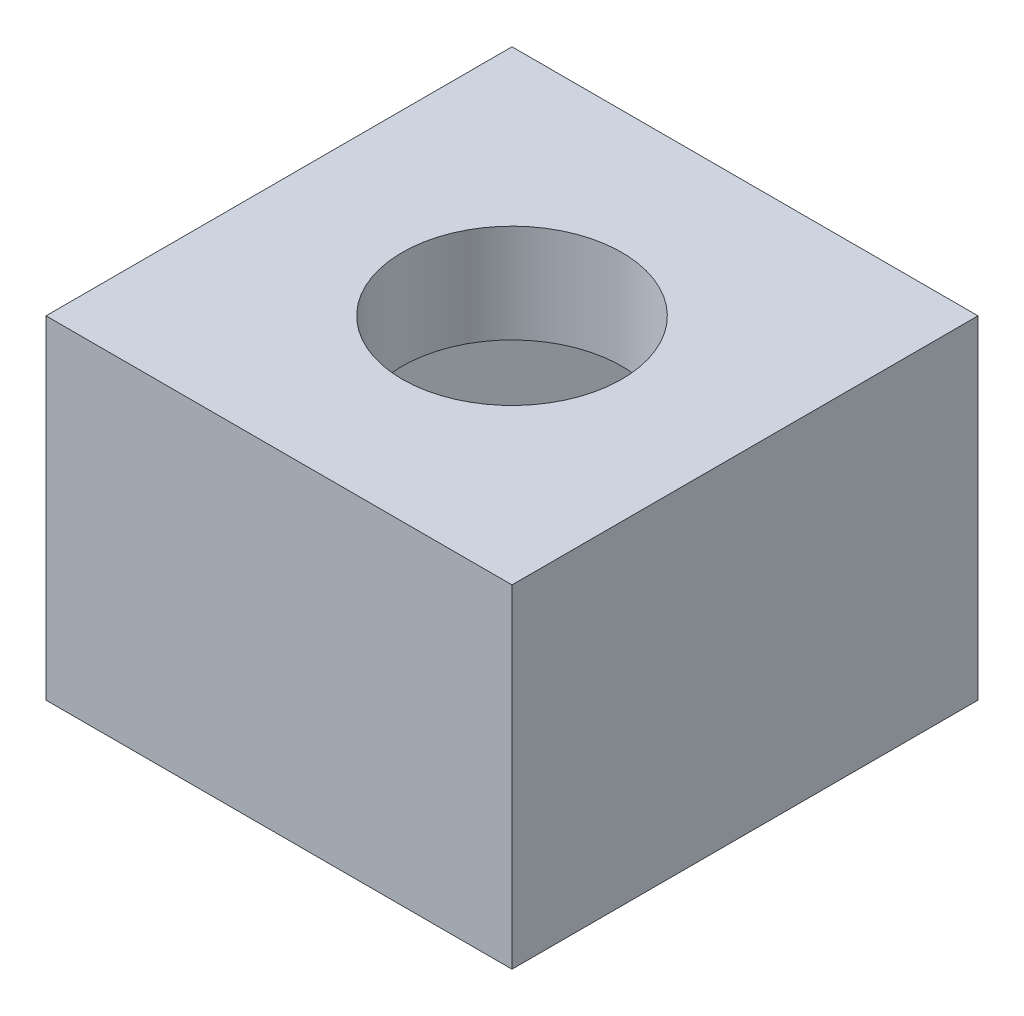
from build123d import *

# Parameters (mm, degrees)
SKETCH1_W           = 7
SKETCH1_H           = 7
BOSS_EXTRUDE1_DEPTH = 5
SKETCH4_R           = 1.65
CUT_EXTRUDE4_DEPTH  = 4
SKETCH6_R           = 1.65
CUT_EXTRUDE6_DEPTH  = 4
SKETCH6_4_R         = 1.65
BOSS_EXTRUDE2_DEPTH = 1.48


with BuildPart() as part:
    # Sketch1 → Boss-Extrude1 (new body)
    with BuildSketch(Plane(origin=(0, 0, 0), x_dir=(1, 0, 0), z_dir=(0, 1, 0))):
        with Locations((-0.67779661, -2.128287226)):
            Rectangle(SKETCH1_W, SKETCH1_H)
    extrude(amount=BOSS_EXTRUDE1_DEPTH)

    # Sketch4 → Cut-Extrude4 (cut)
    with BuildSketch(Plane(origin=(0, 5, 0), x_dir=(1, 0, 0), z_dir=(0, 1, 0))):
        Polygon((-1.544486233, 1.106242481), (-3.912326317, -1.261597603), (-3.045636694, -4.496127311), (0.188893013, -5.362816934), (2.556733098, -2.99497685), (1.690043475, 0.239552858), align=None)
        with Locations((-0.67779661, -2.128287226)):
            Circle(SKETCH4_R, mode=Mode.SUBTRACT)
    extrude(amount=-CUT_EXTRUDE4_DEPTH, mode=Mode.SUBTRACT)

    # Sketch6 → Cut-Extrude6 (cut)
    with BuildSketch(Plane(origin=(0, 5, 0), x_dir=(1, 0, 0), z_dir=(0, 1, 0))):
        with Locations((-0.67779661, -2.128287226)):
            Circle(SKETCH6_R)
    extrude(amount=-CUT_EXTRUDE6_DEPTH, mode=Mode.SUBTRACT)

    # Sketch6_4 → Boss-Extrude2 (add)
    with BuildSketch(Plane(origin=(0, 5, 0), x_dir=(1, 0, 0), z_dir=(0, 1, 0))):
        Polygon((-1.544486233, 1.106242481), (-3.912326317, -1.261597603), (-3.045636694, -4.496127311), (0.188893013, -5.362816934), (2.556733098, -2.99497685), (1.690043475, 0.239552858), align=None)
        with Locations((-0.67779661, -2.128287226)):
            Circle(SKETCH6_4_R, mode=Mode.SUBTRACT)
    extrude(amount=-BOSS_EXTRUDE2_DEPTH)


solid = part.part
